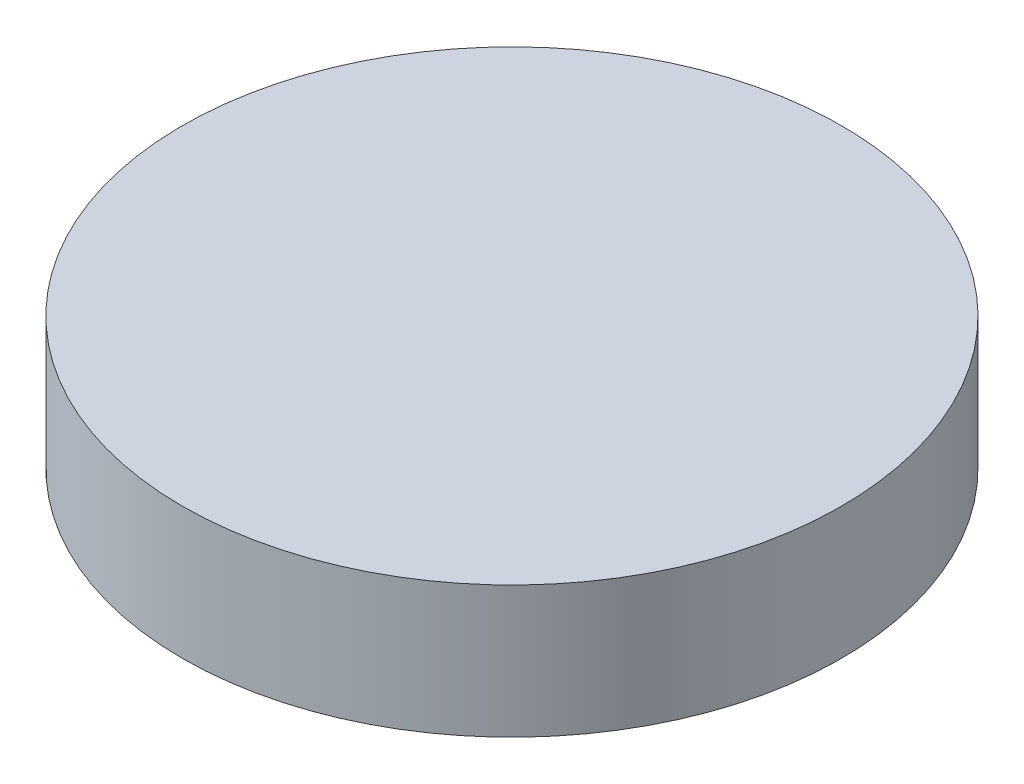
from build123d import *

# Parameters (mm, degrees)
SKETCH1_R           = 6.35
BOSS_EXTRUDE1_DEPTH = 2.54


with BuildPart() as part:
    # Sketch1 → Boss-Extrude1 (new body)
    with BuildSketch(Plane(origin=(0, 0, 0), x_dir=(1, 0, 0), z_dir=(0, 1, 0))):
        Circle(SKETCH1_R)
    extrude(amount=BOSS_EXTRUDE1_DEPTH)


solid = part.part
